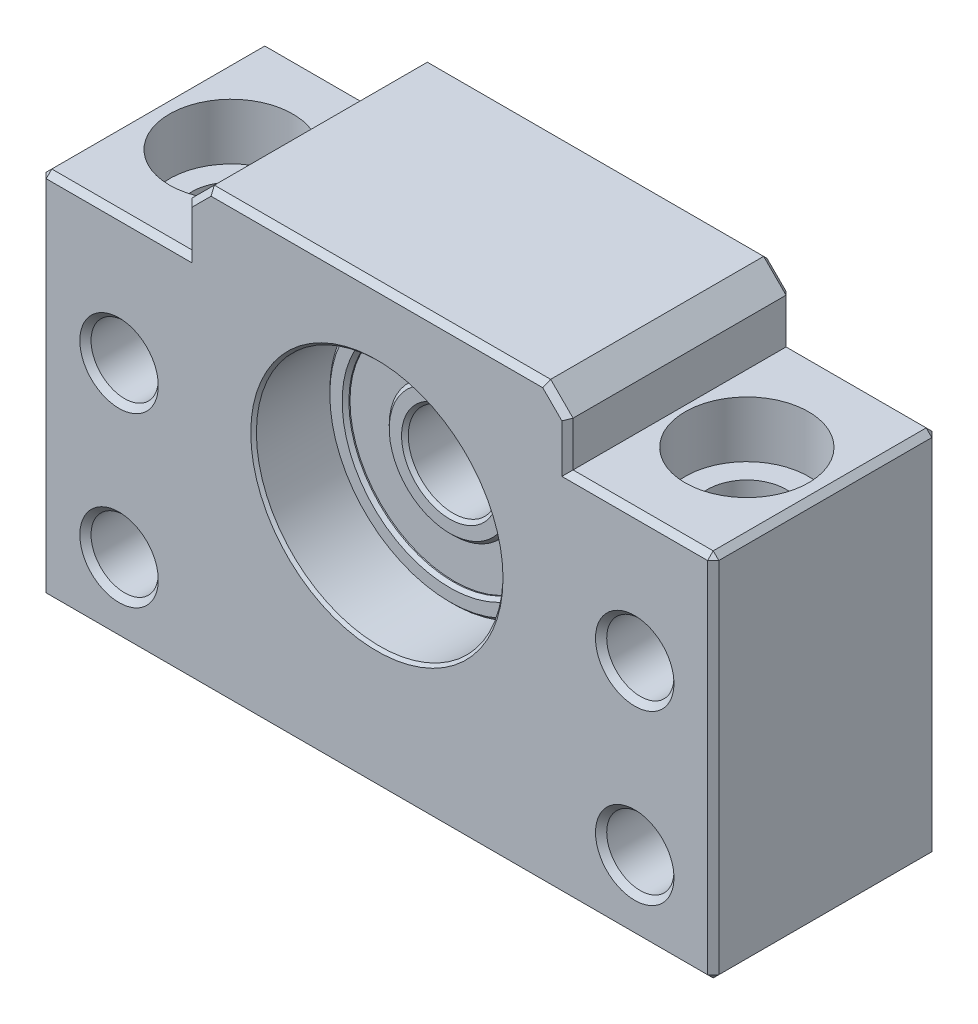
from build123d import *

# Parameters (mm, degrees)
BOSS_EXTRUDE1_DEPTH             = 10
BOSS_EXTRUDE1_DEPTH_BACK        = 10
CHAMFER1_SIZE                   = 2
HOLE_6MM_MOUNT_FRONT_AT_2_COUNT = 2
HOLE_6MM_MOUNT_FRONT_AT_2_PITCH = 15
HOLE_6MM_MOUNT_FRONT_AT_3_COUNT = 2
HOLE_6MM_MOUNT_FRONT_AT_3_PITCH = 48.383881614
HOLE_6MM_MOUNT_FRONT_AT_4_COUNT = 2
HOLE_6MM_MOUNT_FRONT_AT_4_PITCH = 46
HOLES_CAP_AT_2_COUNT            = 2
HOLES_CAP_AT_2_PITCH            = 46
CHAMFER4_SIZE                   = 0.3
CHAMFER6_SIZE                   = 0.5


with BuildPart() as part:
    # Sketch1 → Boss-Extrude1 (new body, two sides)
    with BuildSketch(Plane.XY) as boss_extrude1_sk:
        Polygon((-17, 17), (17, 17), (17, 11), (30, 11), (30, -22), (-30, -22), (-30, 11), (-17, 11), align=None)
    extrude(amount=BOSS_EXTRUDE1_DEPTH)
    extrude(boss_extrude1_sk.sketch, amount=-BOSS_EXTRUDE1_DEPTH_BACK)

    # Chamfer1
    chamfer1_edges = [part.edges().sort_by_distance(p)[0] for p in [
        (-17, 17, 0),
        (17, 17, 0),
    ]]
    chamfer(chamfer1_edges, length=CHAMFER1_SIZE)

    # Sketch6 → hole 22mm bearing (revolve, cut)
    with BuildSketch(Plane(origin=(0, 0, -10), x_dir=(0, 1, 0), z_dir=(1, 0, 0))):
        Polygon((0, 0), (0, 20), (11.25, 20), (11, 19.75), (11, 0.25), (11.25, 0), align=None)
    revolve(axis=Axis((0, 0, -16.35), (0, 0, 1)), mode=Mode.SUBTRACT)

    # Sketch7 → hole 6mm mount front (revolve, cut)
    with BuildSketch(Plane(origin=(23, -0.5, -10), x_dir=(0, 1, 0), z_dir=(1, 0, 0))):
        Polygon((0, 0), (0, 20), (3.5, 20), (3, 19.5), (3, 0.5), (3.5, 0), align=None)
    hole_6mm_mount_front = revolve(axis=Axis((23, -0.5, -16.35), (0, 0, 1)), mode=Mode.SUBTRACT)

    # hole 6mm mount front at 2: hole 6mm mount front ×2
    with Locations(*[(0, -i * HOLE_6MM_MOUNT_FRONT_AT_2_PITCH, 0) for i in range(1, HOLE_6MM_MOUNT_FRONT_AT_2_COUNT)]):
        add(hole_6mm_mount_front, mode=Mode.SUBTRACT)

    # hole 6mm mount front at 3: hole 6mm mount front ×2
    with Locations(*[Vector(-0.950729839, -0.3100206, 0) * (i * HOLE_6MM_MOUNT_FRONT_AT_3_PITCH) for i in range(1, HOLE_6MM_MOUNT_FRONT_AT_3_COUNT)]):
        add(hole_6mm_mount_front, mode=Mode.SUBTRACT)

    # hole 6mm mount front at 4: hole 6mm mount front ×2
    with Locations(*[(-i * HOLE_6MM_MOUNT_FRONT_AT_4_PITCH, 0, 0) for i in range(1, HOLE_6MM_MOUNT_FRONT_AT_4_COUNT)]):
        add(hole_6mm_mount_front, mode=Mode.SUBTRACT)

    # Sketch11 → holes cap (revolve, cut)
    with BuildSketch(Plane(origin=(23, 11, 0), x_dir=(0, 0, 1), z_dir=(1, 0, 0))):
        Polygon((0, 0), (0, 33), (4, 33), (3.5, 32.5), (3.5, 5), (5.5, 5), (5.5, 0), align=None)
    holes_cap = revolve(axis=Axis((23, 17.35, 0), (0, -1, 0)), mode=Mode.SUBTRACT)

    # holes cap at 2: holes cap ×2
    with Locations(*[(-i * HOLES_CAP_AT_2_PITCH, 0, 0) for i in range(1, HOLES_CAP_AT_2_COUNT)]):
        add(holes_cap, mode=Mode.SUBTRACT)

    # Chamfer6
    chamfer6_edges = [part.edges().sort_by_distance(p)[0] for p in [
        (-30, -5.5, -10),
        (0, -22, -10),
        (30, 11, 0),
        (30, -22, 0),
        (-30, -22, 0),
        (-30, 11, 0),
        (30, -5.5, -10),
        (23.5, 11, -10),
        (17, 13, -10),
        (-23.5, 11, 10),
        (-30, -5.5, 10),
        (0, -22, 10),
        (30, -5.5, 10),
        (23.5, 11, 10),
        (17, 13, 10),
        (0, 17, 10),
        (0, 17, -10),
        (-17, 13, 10),
        (16, 16, 10),
        (-16, 16, 10),
        (-17, 13, -10),
        (16, 16, -10),
        (-16, 16, -10),
        (-23.5, 11, -10),
    ]]
    chamfer(chamfer6_edges, length=CHAMFER6_SIZE)


with BuildPart() as body_2:
    # Sketch17 → Revolve2 (revolve)
    with BuildSketch(Plane(origin=(0, 0, 0), x_dir=(1, 0, 0), z_dir=(0, 1, 0))):
        Polygon((-5.7, 3.5), (-4, 3.5), (-4, -3.5), (-5.7, -3.5), (-5.7, -3.1), (-9.3, -3.1), (-9.3, -3.5), (-11, -3.5), (-11, 3.5), (-9.3, 3.5), (-9.3, 3.1), (-5.7, 3.1), align=None)
    revolve(axis=Axis((0, 0, -10), (0, 0, 1)))

    # Chamfer4
    chamfer4_edges = [body_2.edges().sort_by_distance(p)[0] for p in [
        (9.3, 0, 3.5),
        (11, 0, 3.5),
        (5.7, 0, -3.5),
        (4, 0, -3.5),
        (4, 0, 3.5),
        (5.7, 0, 3.5),
    ]]
    chamfer(chamfer4_edges, length=CHAMFER4_SIZE)


solid = Compound([part.part, body_2.part])
